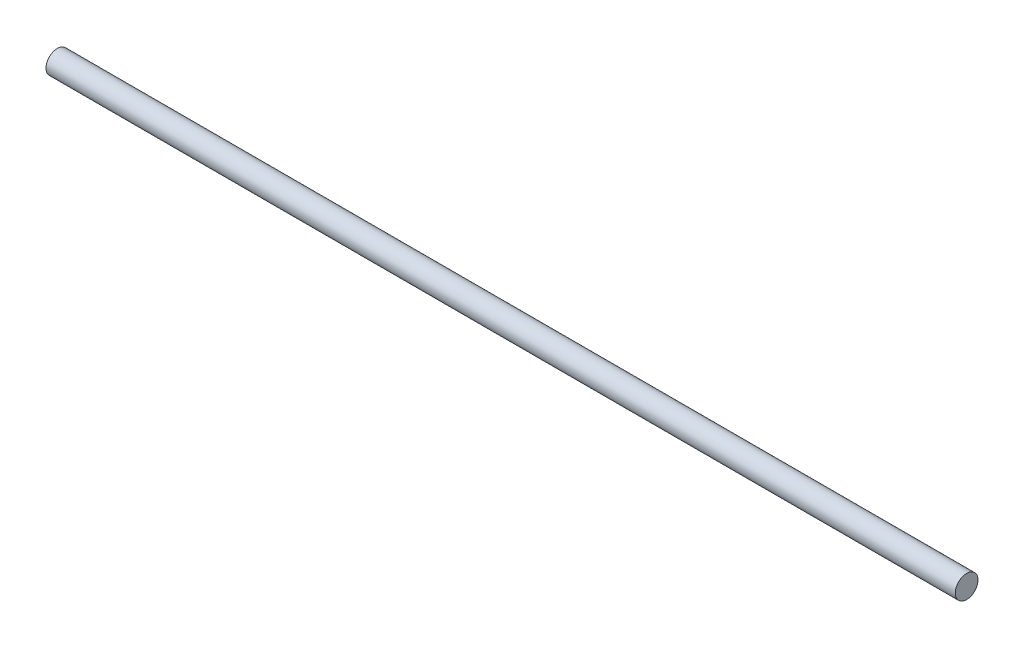
from build123d import *

# Parameters (mm, degrees)
EXTRUDE_1_DEPTH      = 50
EXTRUDE_1_DEPTH_BACK = 50
SKETCH_1_R           = 1.25


with BuildPart() as part:
    # 草图1 → 凸台-拉伸1 (new, two sides: drawn at the far end of the back side and taken through both)
    with BuildSketch(Plane(origin=(0, 0, 0), x_dir=(0, 0, -1), z_dir=(1, 0, 0)).offset(-EXTRUDE_1_DEPTH_BACK)):
        Circle(SKETCH_1_R)
    extrude(amount=EXTRUDE_1_DEPTH + EXTRUDE_1_DEPTH_BACK)


solid = part.part
